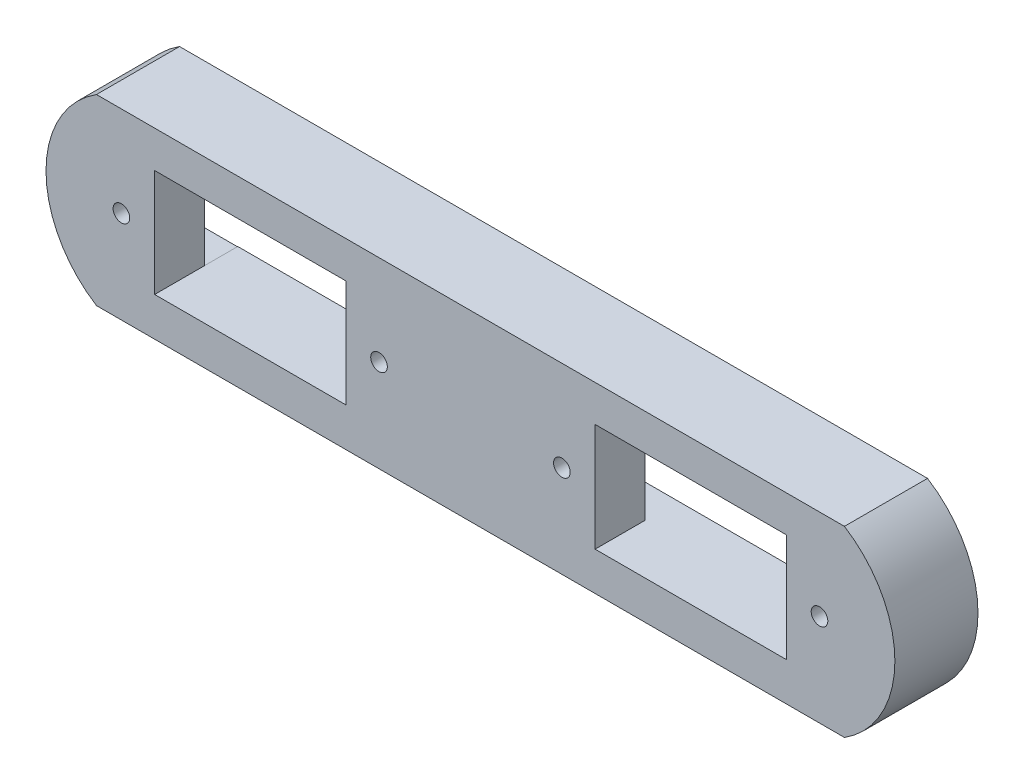
from build123d import *

# Parameters (mm, degrees)
EXTRUDE_2_DEPTH     = 10
SKETCH_2_W          = 5
SKETCH_2_H          = 12.958862493
CUT_EXTRUDE_2_DEPTH = 4
SKETCH_3_W          = 23
SKETCH_3_H          = 13
SKETCH_3_H_2        = 12.917724986
CUT_EXTRUDE_4_DEPTH = 11
SKETCH_4_R          = 1
CUT_EXTRUDE_5_DEPTH = 11


with BuildPart() as part:
    # 草图1 → 凸台-拉伸2 (new body)
    with BuildSketch(Plane.XY):
        with BuildLine():
            Line((-55, 17.378078065), (35, 17.378078065))
            ThreePointArc((35, 17.378078065), (41.07179677, 6.378078065), (35, -4.621921935))
            Line((35, -4.621921935), (-55, -4.621921935))
            ThreePointArc((-55, -4.621921935), (-61.07179677, 6.378078065), (-55, 17.378078065))
        make_face()
    extrude(amount=EXTRUDE_2_DEPTH)

    # 草图2 → 切除-拉伸2 (cut)
    with BuildSketch(Plane(origin=(0, 0, 0), x_dir=(-1, 0, 0), z_dir=(0, 0, -1))):
        with Locations((-30.5, 6.520568754)):
            Rectangle(SKETCH_2_W, SKETCH_2_H)
        with Locations((-2.5, 6.479431247)):
            Rectangle(SKETCH_2_W, SKETCH_2_H)
        with Locations((22.5, 6.520568754)):
            Rectangle(SKETCH_2_W, SKETCH_2_H)
        with Locations((50.5, 6.479431247)):
            Rectangle(SKETCH_2_W, SKETCH_2_H)
    extrude(amount=-CUT_EXTRUDE_2_DEPTH, mode=Mode.SUBTRACT)

    # 草图3 → 切除-拉伸4 (cut, through all)
    with BuildSketch(Plane(origin=(0, 0, 0), x_dir=(-1, 0, 0), z_dir=(0, 0, -1))):
        with Locations((-16.5, 6.5)):
            Rectangle(SKETCH_3_W, SKETCH_3_H)
        with Locations((36.5, 6.5)):
            Rectangle(SKETCH_3_W, SKETCH_3_H_2)
    extrude(amount=-CUT_EXTRUDE_4_DEPTH, mode=Mode.SUBTRACT)

    # 草图4 → 切除-拉伸5 (cut, through all)
    with BuildSketch(Plane(origin=(0, 0, 0), x_dir=(-1, 0, 0), z_dir=(0, 0, -1))):
        with Locations((-32, 6.5)):
            Circle(SKETCH_4_R)
        with Locations((-1, 6.5)):
            Circle(SKETCH_4_R)
        with Locations((21, 6.5)):
            Circle(SKETCH_4_R)
        with Locations((52, 6.5)):
            Circle(SKETCH_4_R)
    extrude(amount=-CUT_EXTRUDE_5_DEPTH, mode=Mode.SUBTRACT)


solid = part.part
